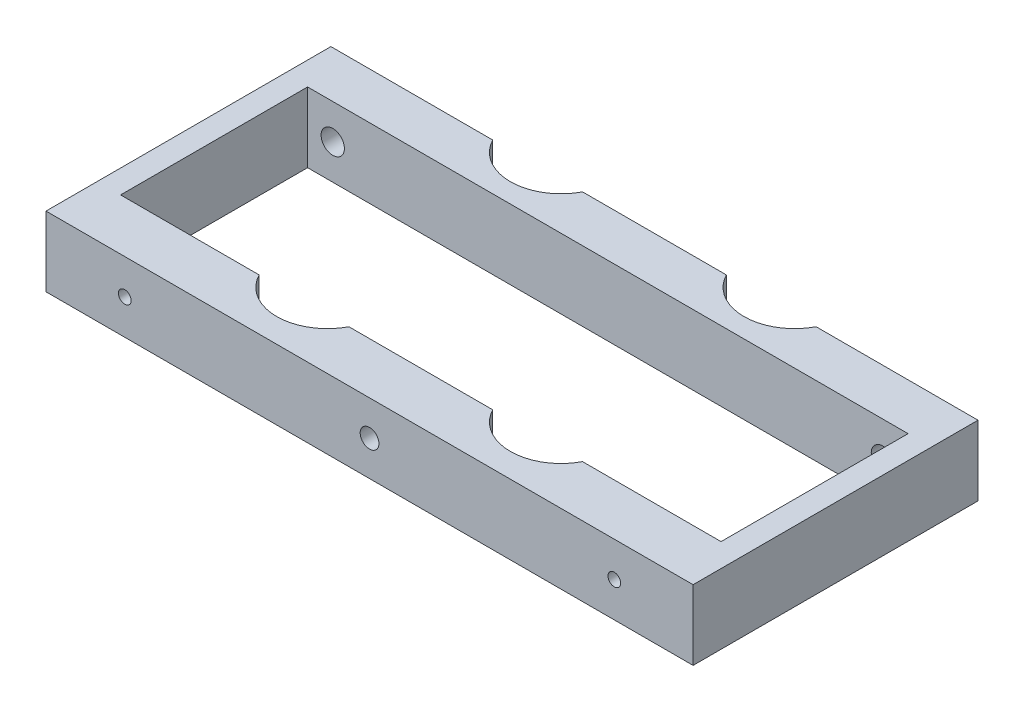
from build123d import *

# Parameters (mm, degrees)
BOSS_EXTRUDE1_DEPTH            = 19.05
F_8_32_TAPPED_HOLE1_D          = 3.4544
F_8_32_TAPPED_HOLE1_DEPTH      = 13.97
F_10_CLEARANCE_HOLE1_D         = 5.1054
F_10_CLEARANCE_HOLE1_DEPTH     = 13.97
F_1_4_0_2500_DOWEL_HOLE2_D     = 6.35
F_1_4_0_2500_DOWEL_HOLE2_DEPTH = 12.7


with BuildPart() as part:
    # Sketch1 → Boss-Extrude1 (new body)
    with BuildSketch(Plane(origin=(0, 0, 0), x_dir=(1, 0, 0), z_dir=(0, 1, 0))):
        with BuildLine():
            Line((107.72869957, 77.6097), (68.54730043, 77.6097))
            ThreePointArc((68.54730043, 77.6097), (56.31815, 70.1802), (44.08899957, 77.6097))
            Line((44.08899957, 77.6097), (0, 77.6097))
            Line((0, 77.6097), (0, 0))
            Line((0, 0), (176.276, 0))
            Line((176.276, 0), (176.276, 77.6097))
            Line((176.276, 77.6097), (132.18700043, 77.6097))
            ThreePointArc((132.18700043, 77.6097), (119.95785, 70.1802), (107.72869957, 77.6097))
        make_face()
        with BuildLine():
            Line((169.926, 13.97), (132.18700043, 13.97))
            ThreePointArc((132.18700043, 13.97), (119.95785, 6.5405), (107.72869957, 13.97))
            Line((107.72869957, 13.97), (68.54730043, 13.97))
            ThreePointArc((68.54730043, 13.97), (56.31815, 6.5405), (44.08899957, 13.97))
            Line((44.08899957, 13.97), (6.35, 13.97))
            Line((6.35, 13.97), (6.35, 64.9097))
            Line((6.35, 64.9097), (169.926, 64.9097))
            Line((169.926, 64.9097), (169.926, 13.97))
        make_face(mode=Mode.SUBTRACT)
    extrude(amount=BOSS_EXTRUDE1_DEPTH)

    # #8-32 Tapped Hole1
    with Locations(Plane.XY):
        with Locations((154.813, 9.525), (21.463, 9.525)):
            Hole(F_8_32_TAPPED_HOLE1_D / 2, depth=F_8_32_TAPPED_HOLE1_DEPTH)

    # #10 Clearance Hole1
    with Locations(Plane.XY):
        with Locations((88.138, 9.525)):
            Hole(F_10_CLEARANCE_HOLE1_D / 2, depth=F_10_CLEARANCE_HOLE1_DEPTH)

    # 1/4 (0.2500) Dowel Hole2
    with Locations(Plane(origin=(0, 0, -77.6097), x_dir=(-1, 0, 0), z_dir=(0, 0, -1))):
        with Locations((-13.208, 9.525), (-163.068, 9.525)):
            Hole(F_1_4_0_2500_DOWEL_HOLE2_D / 2, depth=F_1_4_0_2500_DOWEL_HOLE2_DEPTH)


solid = part.part
